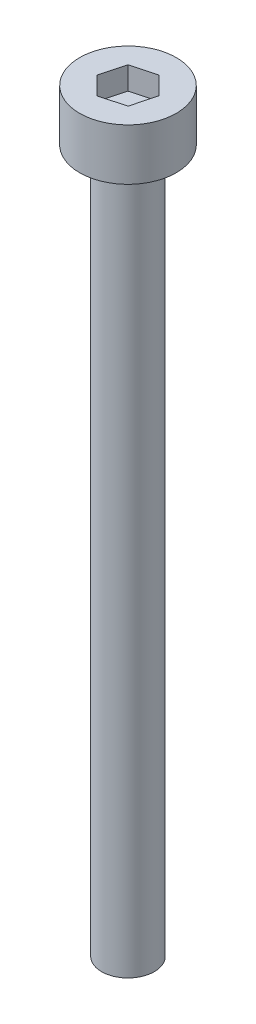
from build123d import *

# Parameters (mm, degrees)
SKETCH_1_R          = 1.5
EXTRUDE_1_DEPTH     = 40
SKETCH_2_R          = 2.75
EXTRUDE_2_DEPTH     = 2.93
CUT_EXTRUDE_1_DEPTH = 1.3


with BuildPart() as part:
    # 草图1 → 凸台-拉伸1 (new body)
    with BuildSketch(Plane(origin=(0, 0, 0), x_dir=(1, 0, 0), z_dir=(0, 1, 0))):
        Circle(SKETCH_1_R)
    extrude(amount=EXTRUDE_1_DEPTH)

    # 草图2 → 凸台-拉伸2 (add)
    with BuildSketch(Plane(origin=(0, 40, 0), x_dir=(1, 0, 0), z_dir=(0, 1, 0))):
        Circle(SKETCH_2_R)
    extrude(amount=EXTRUDE_2_DEPTH)

    # 草图3 → 切除-拉伸1 (cut)
    with BuildSketch(Plane(origin=(0, 42.93, 0), x_dir=(1, 0, 0), z_dir=(0, 1, 0))):
        Polygon((1.024005842, -1.017224346), (1.392945046, 0.378202899), (0.368939204, 1.395427245), (-1.024005842, 1.017224346), (-1.392945046, -0.378202899), (-0.368939204, -1.395427245), align=None)
    extrude(amount=-CUT_EXTRUDE_1_DEPTH, mode=Mode.SUBTRACT)


solid = part.part
